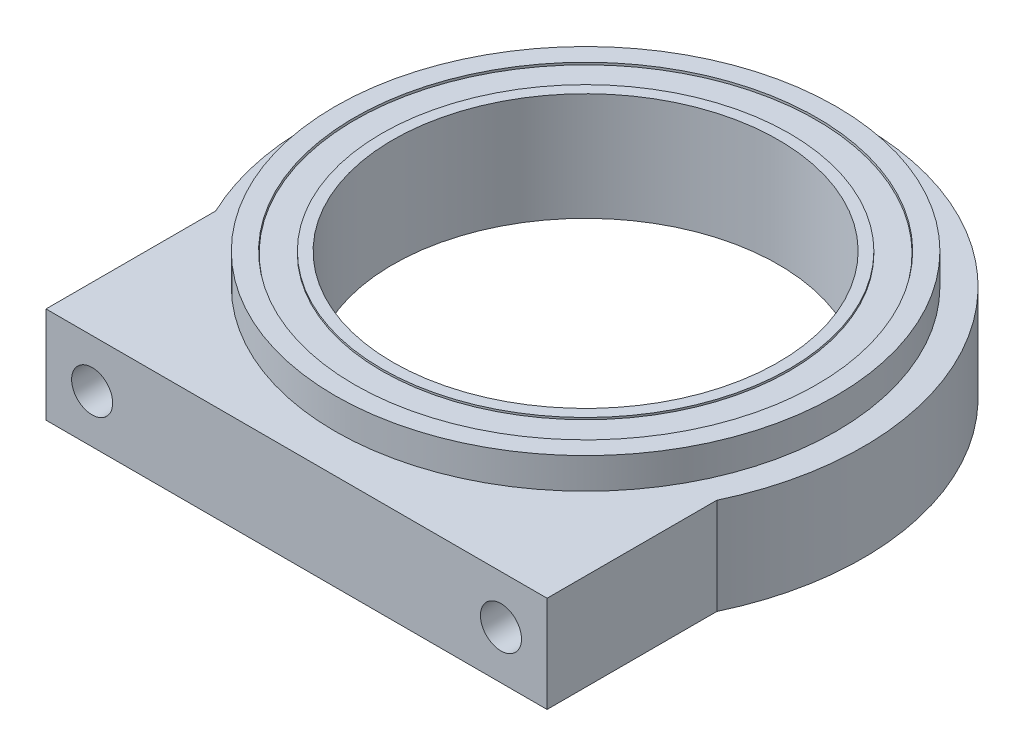
from build123d import *

# Parameters (mm, degrees)
SKETCH1_R                      = 15.875
BOSS_EXTRUDE1_DEPTH            = 3.175
SKETCH2_R                      = 16.51
CUT_EXTRUDE1_DEPTH             = 5.08
SKETCH3_R                      = 16.51
SKETCH3_R_2                    = 15.24
BOSS_EXTRUDE2_DEPTH            = 7.112
SKETCH4_R                      = 15.211059678
SKETCH4_R_2                    = 13.433059678
BOSS_EXTRUDE3_DEPTH            = 5.08
BOSS_EXTRUDE3_DEPTH_BACK       = 1.778
SKETCH5_R                      = 13.433059678
SKETCH5_R_2                    = 12.7
BOSS_EXTRUDE4_DEPTH            = 7.112
F_6_32_TAPPED_HOLE1_AT_2_COUNT = 2
F_6_32_TAPPED_HOLE1_AT_2_PITCH = 26.940768363


with BuildPart() as part:
    # Sketch1 → Boss-Extrude1 (new body, symmetric)
    with BuildSketch(Plane(origin=(0, 0, 0), x_dir=(1, 0, 0), z_dir=(0, 1, 0))):
        with BuildLine():
            Line((-16.51, -19.05), (16.51, -19.05))
            Line((16.51, -19.05), (16.51, -7.865802184))
            ThreePointArc((16.51, -7.865802184), (0, 18.288), (-16.51, -7.865802184))
            Line((-16.51, -7.865802184), (-16.51, -19.05))
        make_face()
        Circle(SKETCH1_R, mode=Mode.SUBTRACT)
    extrude(amount=BOSS_EXTRUDE1_DEPTH, both=True)

    # Sketch2 → Cut-Extrude1 (cut)
    with BuildSketch(Plane(origin=(0, 3.175, 0), x_dir=(1, 0, 0), z_dir=(0, 1, 0))):
        Circle(SKETCH2_R)
    extrude(amount=-CUT_EXTRUDE1_DEPTH, mode=Mode.SUBTRACT)

    # Sketch3 → Boss-Extrude2 (add)
    with BuildSketch(Plane(origin=(0, -1.905, 0), x_dir=(1, 0, 0), z_dir=(0, 1, 0))):
        Circle(SKETCH3_R)
        Circle(SKETCH3_R_2, mode=Mode.SUBTRACT)
    extrude(amount=BOSS_EXTRUDE2_DEPTH)

    # Sketch7 → #6-32 Tapped Hole1 (revolve, cut)
    with BuildSketch(Plane(origin=(13.470384182, 0, 19.05), x_dir=(0, -1, 0), z_dir=(1, 0, 0))):
        Polygon((0, 0), (0, 7.16269403), (1.35255, 6.35), (1.35255, 0), align=None)
    f_6_32_tapped_hole1 = revolve(axis=Axis((13.470384182, 0, 25.4), (0, 0, -1)), mode=Mode.SUBTRACT)

    # #6-32 Tapped Hole1 at 2: #6-32 Tapped Hole1 ×2
    with Locations(*[(-i * F_6_32_TAPPED_HOLE1_AT_2_PITCH, 0, 0) for i in range(1, F_6_32_TAPPED_HOLE1_AT_2_COUNT)]):
        add(f_6_32_tapped_hole1, mode=Mode.SUBTRACT)


with BuildPart() as body_2:
    # Sketch4 → Boss-Extrude3 (new body, two sides)
    with BuildSketch(Plane(origin=(0, 0, 0), x_dir=(1, 0, 0), z_dir=(0, 1, 0))) as boss_extrude3_sk:
        Circle(SKETCH4_R)
        Circle(SKETCH4_R_2, mode=Mode.SUBTRACT)
    extrude(amount=BOSS_EXTRUDE3_DEPTH)
    extrude(boss_extrude3_sk.sketch, amount=-BOSS_EXTRUDE3_DEPTH_BACK)

    # Sketch5 → Boss-Extrude4 (add)
    with BuildSketch(Plane(origin=(0, 5.207, 0), x_dir=(1, 0, 0), z_dir=(0, 1, 0))):
        Circle(SKETCH5_R)
        Circle(SKETCH5_R_2, mode=Mode.SUBTRACT)
    extrude(amount=-BOSS_EXTRUDE4_DEPTH)


solid = Compound([part.part, body_2.part])
